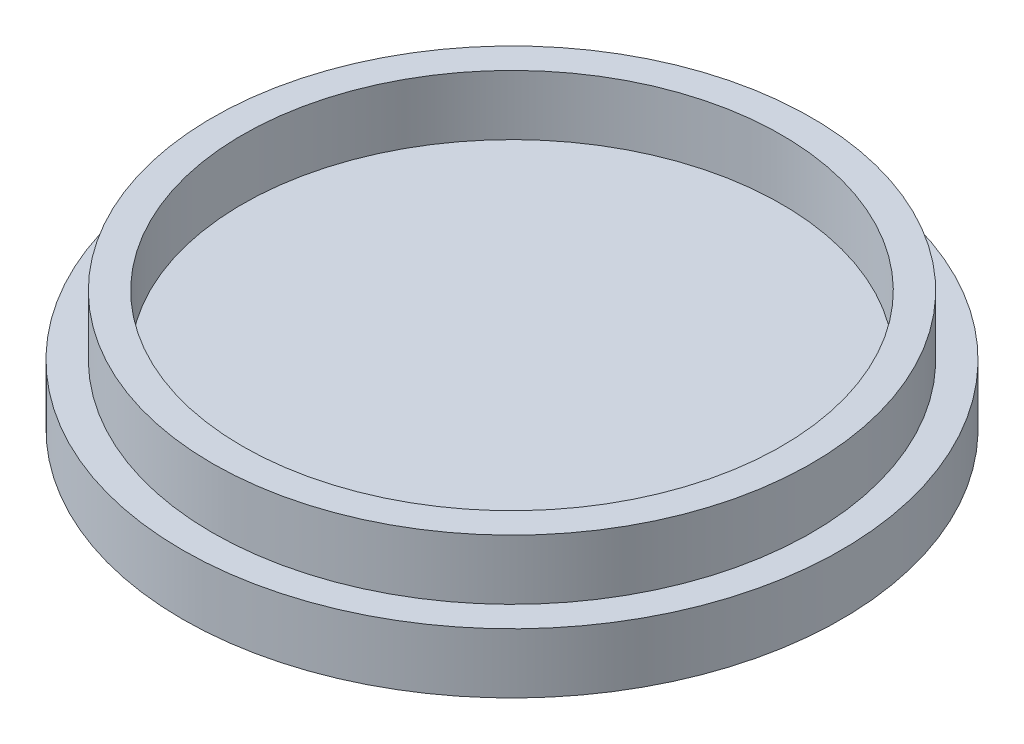
from build123d import *

# Parameters (mm, degrees)
SKETCH1_R           = 27.5
BOSS_EXTRUDE1_DEPTH = 5
SKETCH2_R           = 25
SKETCH2_R_2         = 22.5
BOSS_EXTRUDE2_DEPTH = 5


with BuildPart() as part:
    # Sketch1 → Boss-Extrude1 (new body)
    with BuildSketch(Plane(origin=(0, 0, 0), x_dir=(1, 0, 0), z_dir=(0, 1, 0))):
        with Locations(Location((0, 0, 0), (0, 0, 270))):  # turned: the seam where the file's is
            Circle(SKETCH1_R)
    extrude(amount=BOSS_EXTRUDE1_DEPTH)

    # Sketch2 → Boss-Extrude2 (add)
    with BuildSketch(Plane(origin=(0, 5, 0), x_dir=(1, 0, 0), z_dir=(0, 1, 0))):
        with Locations(Location((0, 0, 0), (0, 0, 270))):  # turned: the seam where the file's is
            Circle(SKETCH2_R)
        with Locations(Location((0, 0, 0), (0, 0, 270))):  # turned: the seam where the file's is
            Circle(SKETCH2_R_2, mode=Mode.SUBTRACT)
    extrude(amount=BOSS_EXTRUDE2_DEPTH)


solid = part.part
